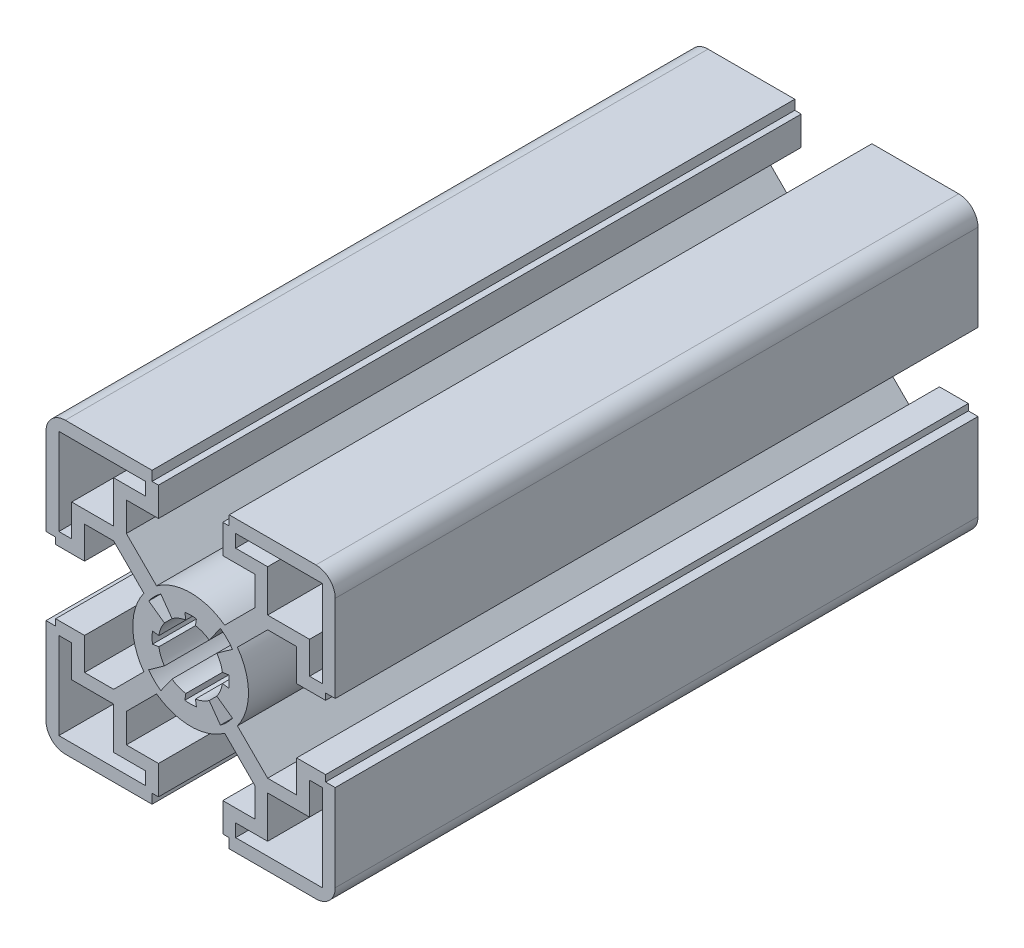
from build123d import *

# Parameters (mm, degrees)
Y_KSEKLIK_EKSTR_ZYON1_DEPTH = 100


with BuildPart() as part:
    # Çizim1 → Yükseklik-Ekstrüzyon1 (new body)
    with BuildSketch(Plane.XY.offset(100)):
        with BuildLine():
            Line((5, -21), (6, -21))
            Line((6, -21), (6, -22.5))
            Line((6, -22.5), (19.5, -22.5))
            ThreePointArc((19.5, -22.5), (21.621320344, -21.621320344), (22.5, -19.5))
            Line((22.5, -19.5), (22.5, -6))
            Line((22.5, -6), (21, -6))
            Line((21, -6), (21, -5))
            Line((21, -5), (16.499999999, -5))
            Line((16.499999999, -5), (16.499999999, -10.000000002))
            Line((16.499999999, -10.000000002), (11.979898986, -10.000000002))
            Line((11.979898986, -10.000000002), (7.27644295, -5.296543966))
            ThreePointArc((7.27644295, -5.296543966), (8.999999998, -2e-09), (7.27644295, 5.296543963))
            Line((7.27644295, 5.296543963), (11.979898987, 10))
            Line((11.979898987, 10), (16.499999999, 10))
            Line((16.499999999, 10), (16.499999999, 5))
            Line((16.499999999, 5), (21, 5))
            Line((21, 5), (21, 6))
            Line((21, 6), (22.5, 6))
            Line((22.5, 6), (22.5, 19.5))
            ThreePointArc((22.5, 19.5), (21.621320344, 21.621320344), (19.5, 22.5))
            Line((19.5, 22.5), (6, 22.5))
            Line((6, 22.5), (6, 21))
            Line((6, 21), (5, 21))
            Line((5, 21), (5, 16.499999998))
            Line((5, 16.499999998), (10, 16.499999998))
            Line((10, 16.499999998), (10, 11.979898987))
            Line((10, 11.979898987), (5.296543963, 7.27644295))
            ThreePointArc((5.296543963, 7.27644295), (-2e-09, 8.999999998), (-5.296543966, 7.27644295))
            Line((-5.296543966, 7.27644295), (-10.000000001, 11.979898985))
            Line((-10.000000001, 11.979898985), (-10.000000001, 16.499999998))
            Line((-10.000000001, 16.499999998), (-5, 16.499999998))
            Line((-5, 16.499999998), (-5, 21))
            Line((-5, 21), (-6, 21))
            Line((-6, 21), (-6, 22.5))
            Line((-6, 22.5), (-19.5, 22.5))
            ThreePointArc((-19.5, 22.5), (-21.621320344, 21.621320344), (-22.5, 19.5))
            Line((-22.5, 19.5), (-22.5, 6))
            Line((-22.5, 6), (-21, 6))
            Line((-21, 6), (-21, 5))
            Line((-21, 5), (-16.500000001, 5))
            Line((-16.500000001, 5), (-16.500000001, 10))
            Line((-16.500000001, 10), (-11.979898987, 10))
            Line((-11.979898987, 10), (-7.276442952, 5.296543965))
            ThreePointArc((-7.276442952, 5.296543965), (-9.000000001, -1e-09), (-7.276442953, -5.296543966))
            Line((-7.276442953, -5.296543966), (-11.979898988, -10.000000002))
            Line((-11.979898988, -10.000000002), (-16.500000001, -10.000000002))
            Line((-16.500000001, -10.000000002), (-16.500000001, -5))
            Line((-16.500000001, -5), (-21, -5))
            Line((-21, -5), (-21, -6))
            Line((-21, -6), (-22.5, -6))
            Line((-22.5, -6), (-22.5, -19.5))
            ThreePointArc((-22.5, -19.5), (-21.621320344, -21.621320344), (-19.5, -22.5))
            Line((-19.5, -22.5), (-6, -22.5))
            Line((-6, -22.5), (-6, -21))
            Line((-6, -21), (-5, -21))
            Line((-5, -21), (-5, -16.500000002))
            Line((-5, -16.500000002), (-10.000000001, -16.500000002))
            Line((-10.000000001, -16.500000002), (-10.000000001, -11.979898989))
            Line((-10.000000001, -11.979898989), (-5.296543966, -7.276442954))
            ThreePointArc((-5.296543966, -7.276442954), (0, -9.000000002), (5.296543965, -7.276442952))
            Line((5.296543965, -7.276442952), (10, -11.979898987))
            Line((10, -11.979898987), (10, -16.500000002))
            Line((10, -16.500000002), (5, -16.500000002))
            Line((5, -16.500000002), (5, -21))
        make_face()
        Polygon((-11.98, 18.500101013), (-11.98, 11.98), (-18.500101013, 11.98), (-18.500101013, 7.000101013), (-20.500101013, 7.000101013), (-20.500101013, 20.500101013), (-7.000101013, 20.500101013), (-7.000101013, 18.500101013), align=None, mode=Mode.SUBTRACT)
        Polygon((-18.500101013, -11.98), (-11.98, -11.98), (-11.98, -18.500101013), (-7.000101013, -18.500101013), (-7.000101013, -20.500101013), (-20.500101013, -20.500101013), (-20.500101013, -7.000101013), (-18.500101013, -7.000101013), align=None, mode=Mode.SUBTRACT)
        Polygon((11.98, -18.500101013), (11.98, -11.98), (18.500101013, -11.98), (18.500101013, -7.000101013), (20.500101013, -7.000101013), (20.500101013, -20.500101013), (7.000101013, -20.500101013), (7.000101013, -18.500101013), align=None, mode=Mode.SUBTRACT)
        Polygon((18.500101013, 11.98), (11.98, 11.98), (11.98, 18.500101013), (7.000101013, 18.500101013), (7.000101013, 20.500101013), (20.500101013, 20.500101013), (20.500101013, 7.000101013), (18.500101013, 7.000101013), align=None, mode=Mode.SUBTRACT)
        with BuildLine():
            Line((-6.52021344, -4.635387443), (-4.075133401, -2.897117152))
            ThreePointArc((-4.075133401, -2.897117152), (-4.635428757, -1.874246585), (-4.943520618, -0.749402378))
            Line((-4.943520618, -0.749402378), (-5.932224741, -0.899282854))
            ThreePointArc((-5.932224741, -0.899282854), (-6.000000002, -2e-09), (-5.932224741, 0.89928285))
            Line((-5.932224741, 0.89928285), (-4.943520618, 0.749402375))
            ThreePointArc((-4.943520618, 0.749402375), (-4.635428757, 1.874246582), (-4.0751334, 2.89711715))
            Line((-4.0751334, 2.89711715), (-6.520213439, 4.635387441))
            ThreePointArc((-6.520213439, 4.635387441), (-5.65685425, 5.656854249), (-4.635387441, 6.520213437))
            Line((-4.635387441, 6.520213437), (-2.897117152, 4.075133398))
            ThreePointArc((-2.897117152, 4.075133398), (-1.874246584, 4.635428754), (-0.749402378, 4.943520614))
            Line((-0.749402378, 4.943520614), (-0.899282853, 5.932224737))
            ThreePointArc((-0.899282853, 5.932224737), (-5e-09, 5.999999998), (0.899282844, 5.932224738))
            Line((0.899282844, 5.932224738), (0.74940237, 4.943520615))
            ThreePointArc((0.74940237, 4.943520615), (1.874246579, 4.635428755), (2.897117149, 4.075133397))
            Line((2.897117149, 4.075133397), (4.635387439, 6.520213436))
            ThreePointArc((4.635387439, 6.520213436), (5.656854248, 5.656854248), (6.520213436, 4.635387439))
            Line((6.520213436, 4.635387439), (4.075133397, 2.897117149))
            ThreePointArc((4.075133397, 2.897117149), (4.635428754, 1.874246581), (4.943520614, 0.749402374))
            Line((4.943520614, 0.749402374), (5.932224737, 0.89928285))
            ThreePointArc((5.932224737, 0.89928285), (5.999999998, -2e-09), (5.932224737, -0.899282854))
            Line((5.932224737, -0.899282854), (4.943520614, -0.749402379))
            ThreePointArc((4.943520614, -0.749402379), (4.635428753, -1.874246586), (4.075133396, -2.897117154))
            Line((4.075133396, -2.897117154), (6.520213435, -4.635387445))
            ThreePointArc((6.520213435, -4.635387445), (5.656854247, -5.656854253), (4.635387438, -6.520213441))
            Line((4.635387438, -6.520213441), (2.897117148, -4.075133401))
            ThreePointArc((2.897117148, -4.075133401), (1.874246581, -4.635428758), (0.749402374, -4.943520618))
            Line((0.749402374, -4.943520618), (0.899282849, -5.932224741))
            ThreePointArc((0.899282849, -5.932224741), (1e-09, -6.000000002), (-0.899282847, -5.932224742))
            Line((-0.899282847, -5.932224742), (-0.749402373, -4.943520619))
            ThreePointArc((-0.749402373, -4.943520619), (-1.874246583, -4.635428758), (-2.897117153, -4.075133401))
            Line((-2.897117153, -4.075133401), (-4.635387443, -6.52021344))
            ThreePointArc((-4.635387443, -6.52021344), (-5.656854252, -5.656854251), (-6.52021344, -4.635387443))
        make_face(mode=Mode.SUBTRACT)
    extrude(amount=-Y_KSEKLIK_EKSTR_ZYON1_DEPTH)


solid = part.part
